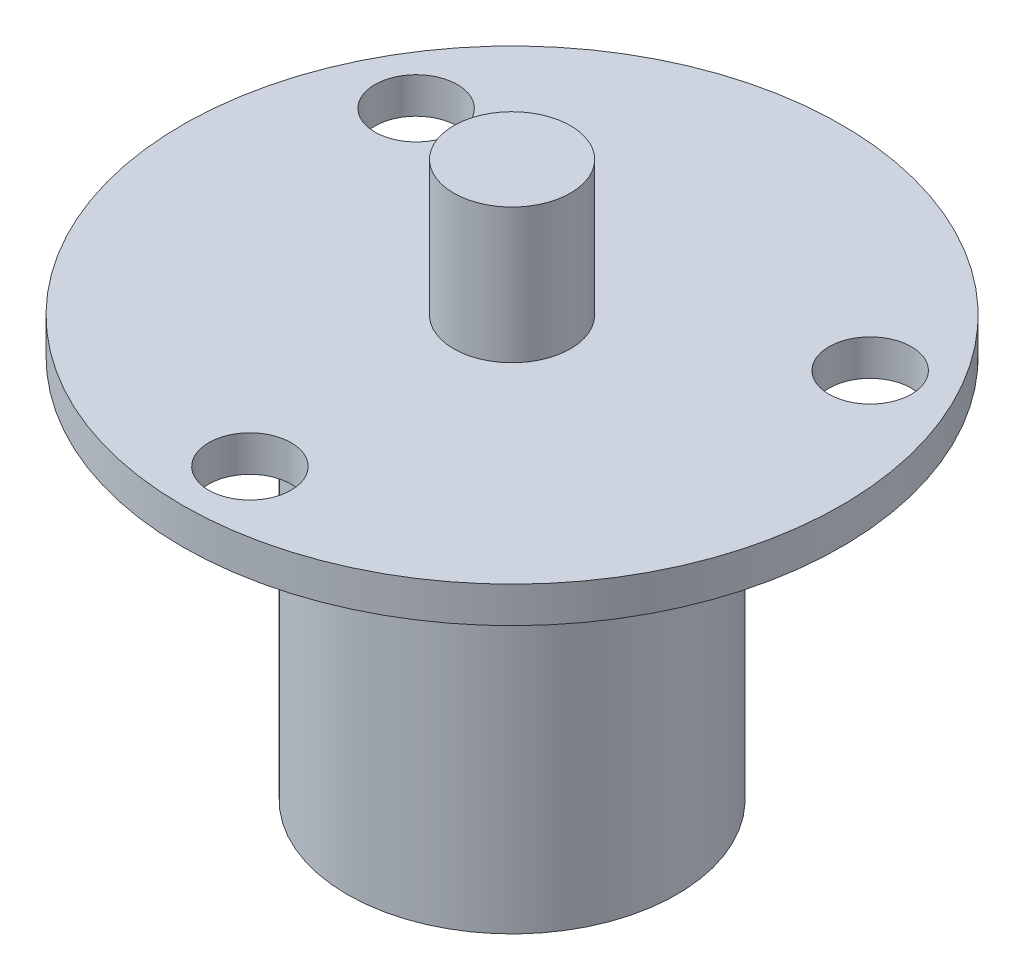
from build123d import *

# Parameters (mm, degrees)
SKETCH1_R           = 22
SKETCH1_R_2         = 2.75
BOSS_EXTRUDE1_DEPTH = 2.4
SKETCH2_R           = 11
BOSS_EXTRUDE2_DEPTH = 25.6
SKETCH3_R           = 3.9
BOSS_EXTRUDE3_DEPTH = 9


with BuildPart() as part:
    # Sketch1 → Boss-Extrude1 (new body)
    with BuildSketch(Plane(origin=(0, 0, 0), x_dir=(1, 0, 0), z_dir=(0, 1, 0))):
        Circle(SKETCH1_R)
        with Locations((-15.155444566, 8.75)):
            Circle(SKETCH1_R_2, mode=Mode.SUBTRACT)
        with Locations((15.155444566, 8.75)):
            Circle(SKETCH1_R_2, mode=Mode.SUBTRACT)
        with Locations((0, -17.5)):
            Circle(SKETCH1_R_2, mode=Mode.SUBTRACT)
    extrude(amount=BOSS_EXTRUDE1_DEPTH)

    # Sketch2 → Boss-Extrude2 (add)
    with BuildSketch(Plane.XZ):
        Circle(SKETCH2_R)
    extrude(amount=BOSS_EXTRUDE2_DEPTH)

    # Sketch3 → Boss-Extrude3 (add)
    with BuildSketch(Plane(origin=(0, 2.4, 0), x_dir=(1, 0, 0), z_dir=(0, 1, 0))):
        Circle(SKETCH3_R)
    extrude(amount=BOSS_EXTRUDE3_DEPTH)


solid = part.part
